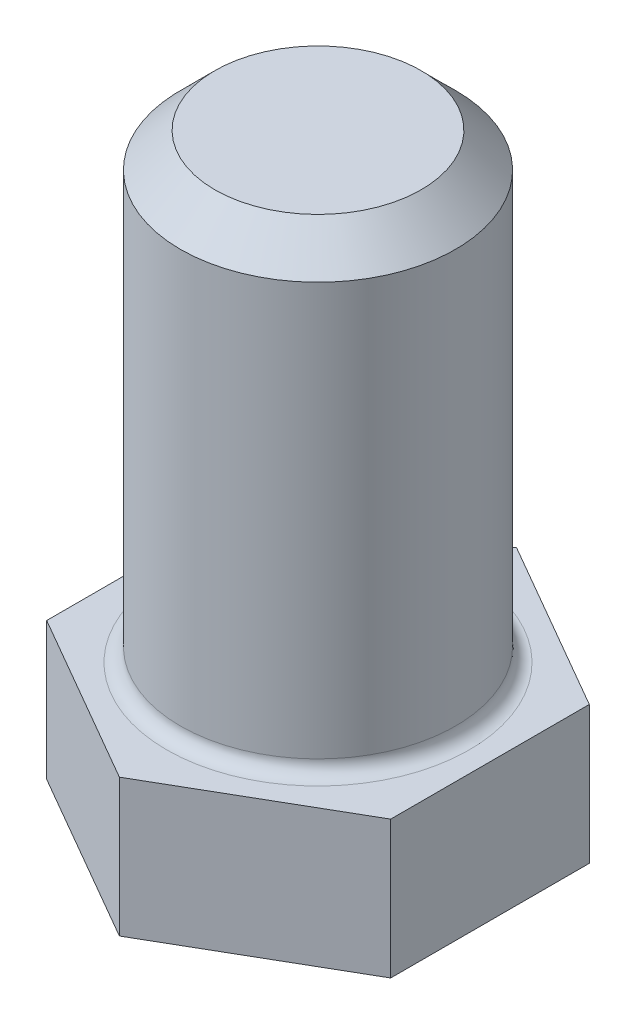
from build123d import *

# Parameters (mm, degrees)
BOSS_EXTRUDE1_DEPTH = 2
SKETCH2_R           = 2
BOSS_EXTRUDE2_DEPTH = 6.7
CHAMFER1_SIZE       = 0.5
FILLET1_R           = 0.2


with BuildPart() as part:
    # Sketch1 → Boss-Extrude1 (new body)
    with BuildSketch(Plane(origin=(0, 0, 0), x_dir=(1, 0, 0), z_dir=(0, 1, 0))):
        Polygon((0, 2.886751346), (-2.5, 1.443375673), (-2.5, -1.443375673), (0, -2.886751346), (2.5, -1.443375673), (2.5, 1.443375673), align=None)
    extrude(amount=BOSS_EXTRUDE1_DEPTH)

    # Sketch2 → Boss-Extrude2 (add)
    with BuildSketch(Plane(origin=(0, 2, 0), x_dir=(1, 0, 0), z_dir=(0, 1, 0))):
        Circle(SKETCH2_R)
    extrude(amount=BOSS_EXTRUDE2_DEPTH)

    # Chamfer1
    chamfer1_edges = [part.edges().sort_by_distance(p)[0] for p in [
        (-2, 8.7, 0),
    ]]
    chamfer(chamfer1_edges, length=CHAMFER1_SIZE)

    # Fillet1
    fillet1_edges = [part.edges().sort_by_distance(p)[0] for p in [
        (-2, 2, 0),
    ]]
    fillet(fillet1_edges, radius=FILLET1_R)


solid = part.part
